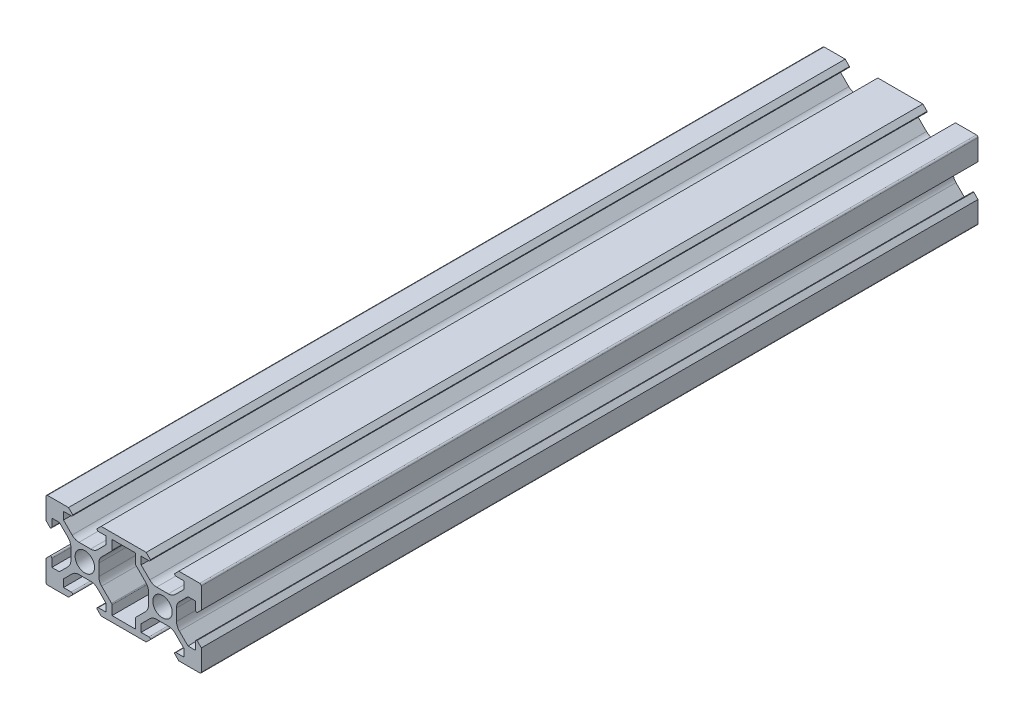
from build123d import *

# Parameters (mm, degrees)
RESSALTO_EXTRUS_O1_DEPTH = 100


with BuildPart() as part:
    # Esboço1 → Ressalto-extrusão1 (new body, symmetric)
    with BuildSketch(Plane.XY):
        with BuildLine():
            Line((-13.1, 8.9), (-14.2, 10))
            Line((-14.2, 10), (-19.6, 10))
            ThreePointArc((-19.6, 10), (-19.882842712, 9.882842712), (-20, 9.6))
            Line((-20, 9.6), (-20, 4.2))
            Line((-20, 4.2), (-18.9, 3.1))
            ThreePointArc((-18.9, 3.1), (-18.617157287, 3.217157287), (-18.5, 3.5))
            Line((-18.5, 3.5), (-18.5, 5.5))
            Line((-18.5, 5.5), (-16.560660172, 5.5))
            Line((-16.560660172, 5.5), (-14.332233047, 3.271572875))
            ThreePointArc((-14.332233047, 3.271572875), (-13.790301169, 2.460514503), (-13.6, 1.503805922))
            Line((-13.6, 1.503805922), (-13.6, 0))
            Line((-13.6, 0), (-13.6, -1.503805922))
            ThreePointArc((-13.6, -1.503805922), (-13.790301169, -2.460514503), (-14.332233047, -3.271572875))
            Line((-14.332233047, -3.271572875), (-16.560660172, -5.5))
            Line((-16.560660172, -5.5), (-18.5, -5.5))
            Line((-18.5, -5.5), (-18.5, -3.5))
            ThreePointArc((-18.5, -3.5), (-18.617157287, -3.217157288), (-18.9, -3.1))
            Line((-18.9, -3.1), (-20, -4.2))
            Line((-20, -4.2), (-20, -9.6))
            ThreePointArc((-20, -9.6), (-19.882842712, -9.882842712), (-19.6, -10))
            Line((-19.6, -10), (-14.2, -10))
            Line((-14.2, -10), (-13.1, -8.9))
            ThreePointArc((-13.1, -8.9), (-13.217157287, -8.617157288), (-13.5, -8.5))
            Line((-13.5, -8.5), (-15.5, -8.5))
            Line((-15.5, -8.5), (-15.5, -6.560660172))
            Line((-15.5, -6.560660172), (-13.271572875, -4.332233047))
            ThreePointArc((-13.271572875, -4.332233047), (-12.460514503, -3.790301169), (-11.503805922, -3.6))
            Line((-11.503805922, -3.6), (-10, -3.6))
            Line((-10, -3.6), (-8.496194078, -3.6))
            ThreePointArc((-8.496194078, -3.6), (-7.539485497, -3.790301169), (-6.728427125, -4.332233047))
            Line((-6.728427125, -4.332233047), (-4.5, -6.560660172))
            Line((-4.5, -6.560660172), (-4.5, -8.5))
            Line((-4.5, -8.5), (-6.5, -8.5))
            ThreePointArc((-6.5, -8.5), (-6.782842712, -8.617157288), (-6.9, -8.9))
            Line((-6.9, -8.9), (-5.8, -10))
            Line((-5.8, -10), (5.8, -10))
            Line((5.8, -10), (6.9, -8.9))
            ThreePointArc((6.9, -8.9), (6.782842712, -8.617157288), (6.5, -8.5))
            Line((6.5, -8.5), (4.5, -8.5))
            Line((4.5, -8.5), (4.5, -6.560660172))
            Line((4.5, -6.560660172), (6.728427125, -4.332233047))
            ThreePointArc((6.728427125, -4.332233047), (7.539485497, -3.790301169), (8.496194078, -3.6))
            Line((8.496194078, -3.6), (10, -3.6))
            Line((10, -3.6), (11.503805922, -3.6))
            ThreePointArc((11.503805922, -3.6), (12.460514503, -3.790301169), (13.271572875, -4.332233047))
            Line((13.271572875, -4.332233047), (15.5, -6.560660172))
            Line((15.5, -6.560660172), (15.5, -8.5))
            Line((15.5, -8.5), (13.5, -8.5))
            ThreePointArc((13.5, -8.5), (13.217157287, -8.617157288), (13.1, -8.9))
            Line((13.1, -8.9), (14.2, -10))
            Line((14.2, -10), (19.6, -10))
            ThreePointArc((19.6, -10), (19.882842712, -9.882842712), (20, -9.6))
            Line((20, -9.6), (20, -4.2))
            Line((20, -4.2), (18.9, -3.1))
            ThreePointArc((18.9, -3.1), (18.617157287, -3.217157288), (18.5, -3.5))
            Line((18.5, -3.5), (18.5, -5.5))
            Line((18.5, -5.5), (16.560660172, -5.5))
            Line((16.560660172, -5.5), (14.332233047, -3.271572875))
            ThreePointArc((14.332233047, -3.271572875), (13.790301169, -2.460514503), (13.6, -1.503805922))
            Line((13.6, -1.503805922), (13.6, 0))
            Line((13.6, 0), (13.6, 1.503805922))
            ThreePointArc((13.6, 1.503805922), (13.790301169, 2.460514503), (14.332233047, 3.271572875))
            Line((14.332233047, 3.271572875), (16.560660172, 5.5))
            Line((16.560660172, 5.5), (18.5, 5.5))
            Line((18.5, 5.5), (18.5, 3.5))
            ThreePointArc((18.5, 3.5), (18.617157287, 3.217157287), (18.9, 3.1))
            Line((18.9, 3.1), (20, 4.2))
            Line((20, 4.2), (20, 9.6))
            ThreePointArc((20, 9.6), (19.882842712, 9.882842712), (19.6, 10))
            Line((19.6, 10), (14.2, 10))
            Line((14.2, 10), (13.1, 8.9))
            ThreePointArc((13.1, 8.9), (13.217157287, 8.617157287), (13.5, 8.5))
            Line((13.5, 8.5), (15.5, 8.5))
            Line((15.5, 8.5), (15.5, 6.560660172))
            Line((15.5, 6.560660172), (13.271572875, 4.332233047))
            ThreePointArc((13.271572875, 4.332233047), (12.460514503, 3.790301169), (11.503805922, 3.6))
            Line((11.503805922, 3.6), (10, 3.6))
            Line((10, 3.6), (8.496194078, 3.6))
            ThreePointArc((8.496194078, 3.6), (7.539485497, 3.790301169), (6.728427125, 4.332233047))
            Line((6.728427125, 4.332233047), (4.5, 6.560660172))
            Line((4.5, 6.560660172), (4.5, 8.5))
            Line((4.5, 8.5), (6.5, 8.5))
            ThreePointArc((6.5, 8.5), (6.782842712, 8.617157288), (6.9, 8.9))
            Line((6.9, 8.9), (5.8, 10))
            Line((5.8, 10), (-5.8, 10))
            Line((-5.8, 10), (-6.9, 8.9))
            ThreePointArc((-6.9, 8.9), (-6.782842712, 8.617157288), (-6.5, 8.5))
            Line((-6.5, 8.5), (-4.5, 8.5))
            Line((-4.5, 8.5), (-4.5, 6.560660172))
            Line((-4.5, 6.560660172), (-6.728427125, 4.332233047))
            ThreePointArc((-6.728427125, 4.332233047), (-7.539485497, 3.790301169), (-8.496194078, 3.6))
            Line((-8.496194078, 3.6), (-10, 3.6))
            Line((-10, 3.6), (-11.503805922, 3.6))
            ThreePointArc((-11.503805922, 3.6), (-12.460514503, 3.790301169), (-13.271572875, 4.332233047))
            Line((-13.271572875, 4.332233047), (-15.5, 6.560660172))
            Line((-15.5, 6.560660172), (-15.5, 8.5))
            Line((-15.5, 8.5), (-13.5, 8.5))
            ThreePointArc((-13.5, 8.5), (-13.217157287, 8.617157287), (-13.1, 8.9))
        make_face()
        with BuildLine():
            Line((-3, 8.5), (3, 8.5))
            Line((3, 8.5), (3, 6.105025253))
            ThreePointArc((3, 6.105025253), (3.030448187, 5.95195188), (3.117157288, 5.822182541))
            Line((3.117157288, 5.822182541), (5.667766953, 3.271572875))
            ThreePointArc((5.667766953, 3.271572875), (6.209698831, 2.460514503), (6.4, 1.503805922))
            Line((6.4, 1.503805922), (6.4, 0))
            Line((6.4, 0), (6.4, -1.503805922))
            ThreePointArc((6.4, -1.503805922), (6.209698831, -2.460514503), (5.667766953, -3.271572875))
            Line((5.667766953, -3.271572875), (3.117157288, -5.822182541))
            ThreePointArc((3.117157288, -5.822182541), (3.030448187, -5.95195188), (3, -6.105025253))
            Line((3, -6.105025253), (3, -8.5))
            Line((3, -8.5), (-3, -8.5))
            Line((-3, -8.5), (-3, -6.105025253))
            ThreePointArc((-3, -6.105025253), (-3.030448187, -5.95195188), (-3.117157288, -5.822182541))
            Line((-3.117157288, -5.822182541), (-5.667766953, -3.271572875))
            ThreePointArc((-5.667766953, -3.271572875), (-6.209698831, -2.460514503), (-6.4, -1.503805922))
            Line((-6.4, -1.503805922), (-6.4, 0))
            Line((-6.4, 0), (-6.4, 1.503805922))
            ThreePointArc((-6.4, 1.503805922), (-6.209698831, 2.460514503), (-5.667766953, 3.271572875))
            Line((-5.667766953, 3.271572875), (-3.117157288, 5.822182541))
            ThreePointArc((-3.117157288, 5.822182541), (-3.030448187, 5.95195188), (-3, 6.105025253))
            Line((-3, 6.105025253), (-3, 8.5))
        make_face(mode=Mode.SUBTRACT)
        with BuildLine():
            ThreePointArc((-10, 2.5), (-11.767766953, 1.767766953), (-12.5, 0))
            ThreePointArc((-12.5, 0), (-11.767766953, -1.767766953), (-10, -2.5))
            ThreePointArc((-10, -2.5), (-8.232233047, -1.767766953), (-7.5, 0))
            ThreePointArc((-7.5, 0), (-8.232233047, 1.767766953), (-10, 2.5))
        make_face(mode=Mode.SUBTRACT)
        with BuildLine():
            ThreePointArc((12.5, 0), (11.767766953, -1.767766953), (10, -2.5))
            ThreePointArc((10, -2.5), (8.232233047, -1.767766953), (7.5, 0))
            ThreePointArc((7.5, 0), (8.232233047, 1.767766953), (10, 2.5))
            ThreePointArc((10, 2.5), (11.767766953, 1.767766953), (12.5, 0))
        make_face(mode=Mode.SUBTRACT)
    extrude(amount=RESSALTO_EXTRUS_O1_DEPTH, both=True)


solid = part.part
